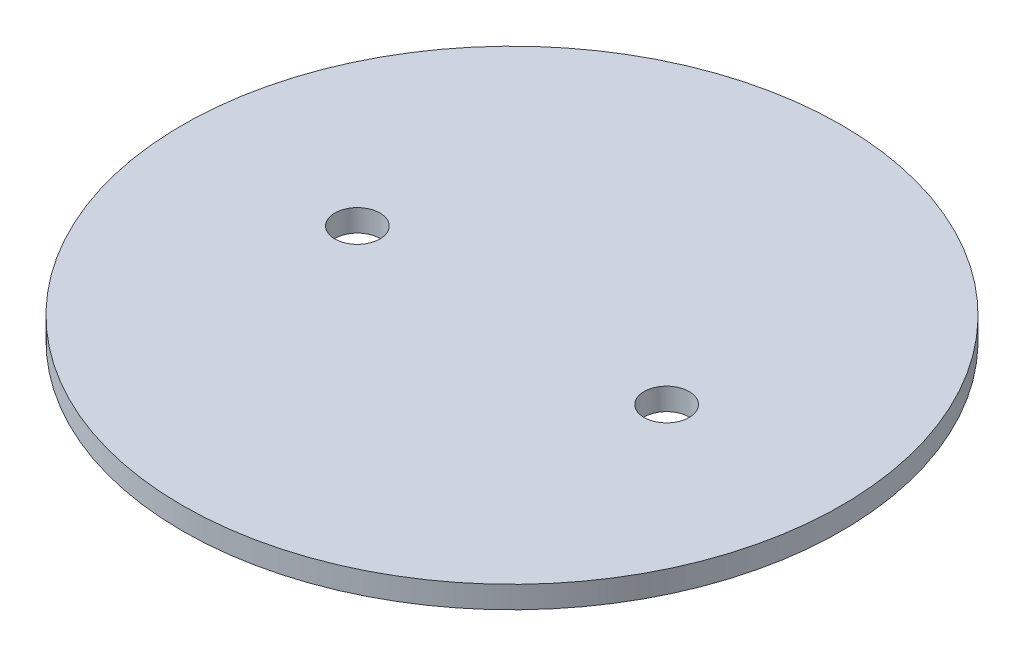
from build123d import *

# Parameters (mm, degrees)
SKETCH1_R           = 47.371
SKETCH1_R_2         = 3.2385
BOSS_EXTRUDE1_DEPTH = 3.175


with BuildPart() as part:
    # Sketch1 → Boss-Extrude1 (new body)
    with BuildSketch(Plane(origin=(0, 0, 0), x_dir=(1, 0, 0), z_dir=(0, 1, 0))):
        Circle(SKETCH1_R)
        with Locations((22.225, 0)):
            Circle(SKETCH1_R_2, mode=Mode.SUBTRACT)
        with Locations((-22.225, 0)):
            Circle(SKETCH1_R_2, mode=Mode.SUBTRACT)
    extrude(amount=BOSS_EXTRUDE1_DEPTH)


solid = part.part
